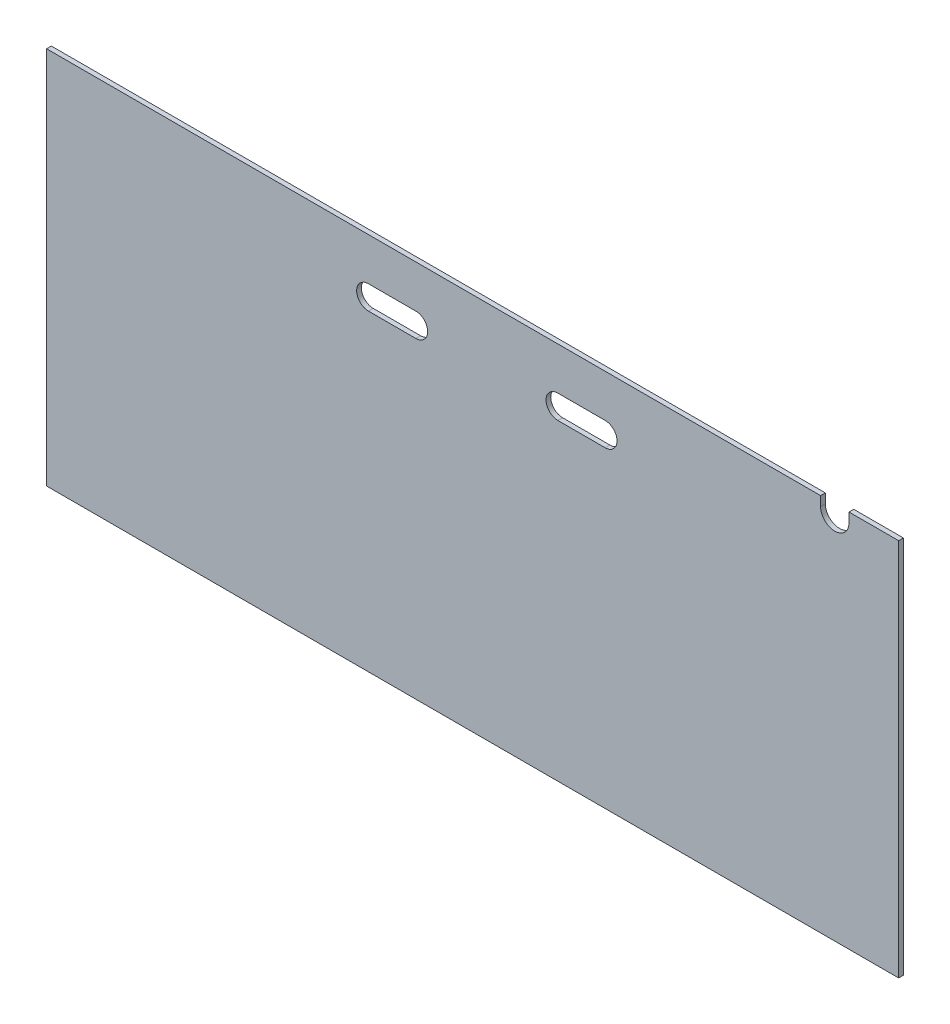
from build123d import *

# Parameters (mm, degrees)
SKETCH1_W           = 1143
SKETCH1_H           = 508
BOSS_EXTRUDE1_DEPTH = 6.35
CUT_EXTRUDE1_DEPTH  = 7.35
CUT_EXTRUDE2_DEPTH  = 7.35


with BuildPart() as part:
    # Sketch1 → Boss-Extrude1 (new body)
    with BuildSketch(Plane.XY):
        with Locations((571.5, 254)):
            Rectangle(SKETCH1_W, SKETCH1_H)
    extrude(amount=BOSS_EXTRUDE1_DEPTH)

    # Sketch2 → Cut-Extrude1 (cut, through all)
    with BuildSketch(Plane.XY.offset(6.35)):
        with BuildLine():
            Line((431.8, 450.85), (495.3, 450.85))
            ThreePointArc((495.3, 450.85), (511.175, 434.975), (495.3, 419.1))
            Line((495.3, 419.1), (431.8, 419.1))
            ThreePointArc((431.8, 419.1), (415.925, 434.975), (431.8, 450.85))
        make_face()
        with BuildLine():
            Line((685.8, 450.85), (749.3, 450.85))
            ThreePointArc((749.3, 450.85), (765.175, 434.975), (749.3, 419.1))
            Line((749.3, 419.1), (685.8, 419.1))
            ThreePointArc((685.8, 419.1), (669.925, 434.975), (685.8, 450.85))
        make_face()
    extrude(amount=-CUT_EXTRUDE1_DEPTH, mode=Mode.SUBTRACT)

    # Sketch6 → Cut-Extrude2 (cut, through all)
    with BuildSketch(Plane.XY.offset(6.35)):
        with BuildLine():
            Line((1038.225, 508), (1076.325, 508))
            Line((1076.325, 508), (1076.325, 495.3))
            ThreePointArc((1076.325, 495.3), (1057.275, 476.25), (1038.225, 495.3))
            Line((1038.225, 495.3), (1038.225, 508))
        make_face()
    extrude(amount=-CUT_EXTRUDE2_DEPTH, mode=Mode.SUBTRACT)


solid = part.part
